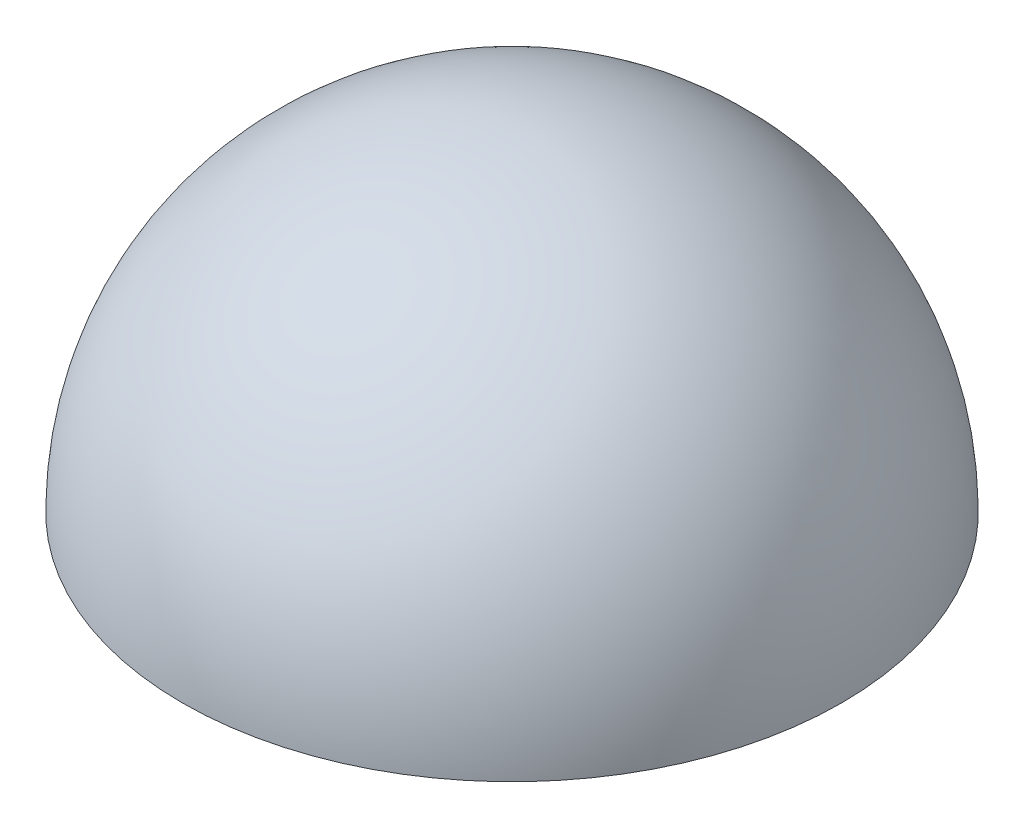
from build123d import *


with BuildPart() as part:
    # Sketch1 → Revolve1 (revolve)
    with BuildSketch(Plane.XY):
        with BuildLine():
            Line((0, 3.2), (0, 3.8))
            ThreePointArc((0, 3.8), (2.687005769, 2.687005769), (3.8, 0))
            Line((3.8, 0), (3.2, 0))
            ThreePointArc((3.2, 0), (2.2627417, 2.2627417), (0, 3.2))
        make_face()
    revolve(axis=Axis((0, 3.1, 0), (0, -1, 0)))


with BuildPart() as body_2:
    # Sketch2 → Revolve2 (revolve)
    with BuildSketch(Plane.XY):
        with BuildLine():
            Line((0, 3.1), (0, 0))
            Line((0, 0), (3.1, 0))
            ThreePointArc((3.1, 0), (2.192031022, 2.192031022), (0, 3.1))
        make_face()
    revolve(axis=Axis((0, 3.1, 0), (0, -1, 0)))


solid = Compound([part.part, body_2.part])
